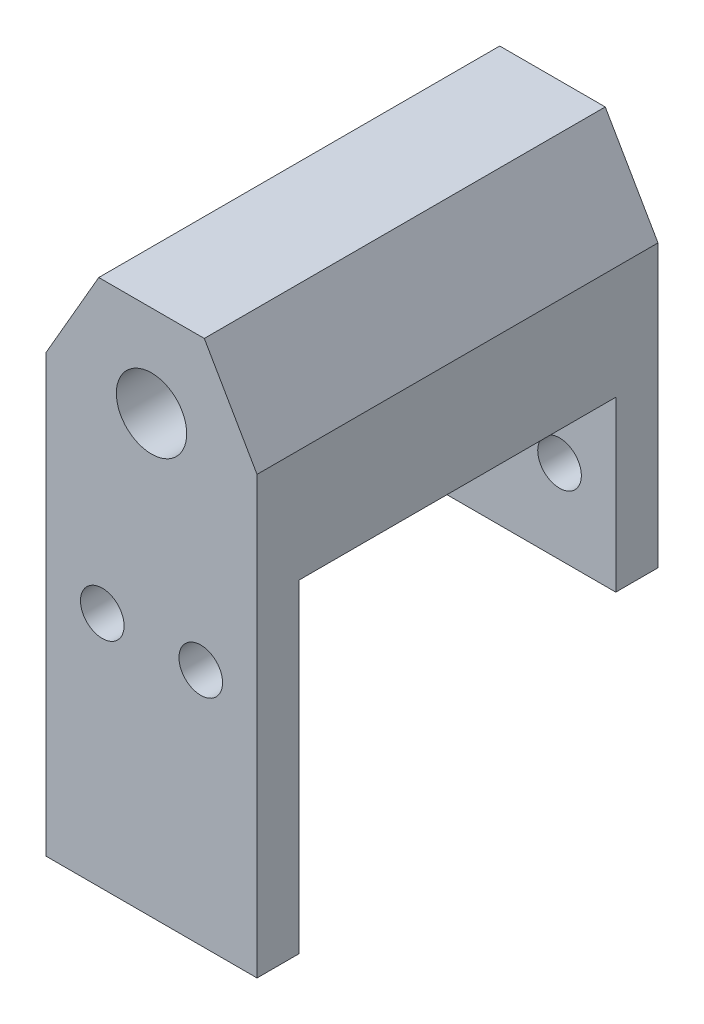
from build123d import *

# Parameters (mm, degrees)
BOSS_EXTRUDE1_DEPTH   = 28.5
SKETCH2_W             = 15
SKETCH2_H             = 3
BOSS_EXTRUDE2_DEPTH   = 23
SKETCH2_3_W           = 15
SKETCH2_3_H           = 3
BOSS_EXTRUDE3_DEPTH   = 12
SKETCH5_R             = 1.55
CUT_EXTRUDE1_DEPTH    = 43.772654816
M6_TAPPED_HOLE1_D     = 5
M6_TAPPED_HOLE1_DEPTH = 8
M6_TAPPED_HOLE1_TIP   = 1.502151548
M6_TAPPED_HOLE2_D     = 5
M6_TAPPED_HOLE2_DEPTH = 6
M6_TAPPED_HOLE2_TIP   = 1.502151548
SKETCH6_R             = 2.5
CUT_EXTRUDE2_DEPTH    = 43.772654816


with BuildPart() as part:
    # Sketch1 → Boss-Extrude1 (new body)
    with BuildSketch(Plane.XY):
        Polygon((-7.5, 0), (-7.5, -8), (7.5, -8), (7.5, 0), (3.75, 6.495190528), (-3.75, 6.495190528), align=None)
    extrude(amount=BOSS_EXTRUDE1_DEPTH)

    # Sketch2 → Boss-Extrude2 (add)
    with BuildSketch(Plane.XZ.offset(8)):
        with Locations((0, 27)):
            Rectangle(SKETCH2_W, SKETCH2_H)
    extrude(amount=BOSS_EXTRUDE2_DEPTH)

    # Sketch2_3 → Boss-Extrude3 (add)
    with BuildSketch(Plane.XZ.offset(8)):
        with Locations((0, 1.5)):
            Rectangle(SKETCH2_3_W, SKETCH2_3_H)
    extrude(amount=BOSS_EXTRUDE3_DEPTH)

    # Sketch5 → Cut-Extrude1 (cut, through all)
    with BuildSketch(Plane(origin=(0, 0, 0), x_dir=(-1, 0, 0), z_dir=(0, 0, -1))):
        with Locations((-3.5, -14.05)):
            Circle(SKETCH5_R)
        with Locations((3.5, -14.05)):
            Circle(SKETCH5_R)
    extrude(amount=-CUT_EXTRUDE1_DEPTH, mode=Mode.SUBTRACT)

    # M6 Tapped Hole1
    with Locations(Plane(origin=(0, 0, 0), x_dir=(-1, 0, 0), z_dir=(0, 0, -1))):
        with Locations((0, 0)):
            Hole(M6_TAPPED_HOLE1_D / 2, depth=M6_TAPPED_HOLE1_DEPTH)
            with Locations((0, 0, -(M6_TAPPED_HOLE1_DEPTH + M6_TAPPED_HOLE1_TIP / 2))):  # 118° drill point
                Cone(0, M6_TAPPED_HOLE1_D / 2, M6_TAPPED_HOLE1_TIP, mode=Mode.SUBTRACT)

    # M6 Tapped Hole2
    with Locations(Plane.XY.offset(28.5)):
        with Locations((0, 0)):
            Hole(M6_TAPPED_HOLE2_D / 2, depth=M6_TAPPED_HOLE2_DEPTH)
            with Locations((0, 0, -(M6_TAPPED_HOLE2_DEPTH + M6_TAPPED_HOLE2_TIP / 2))):  # 118° drill point
                Cone(0, M6_TAPPED_HOLE2_D / 2, M6_TAPPED_HOLE2_TIP, mode=Mode.SUBTRACT)

    # Sketch6 → Cut-Extrude2 (cut, through all)
    with BuildSketch(Plane(origin=(0, 0, 0), x_dir=(-1, 0, 0), z_dir=(0, 0, -1))):
        Circle(SKETCH6_R)
    extrude(amount=-CUT_EXTRUDE2_DEPTH, mode=Mode.SUBTRACT)


solid = part.part
